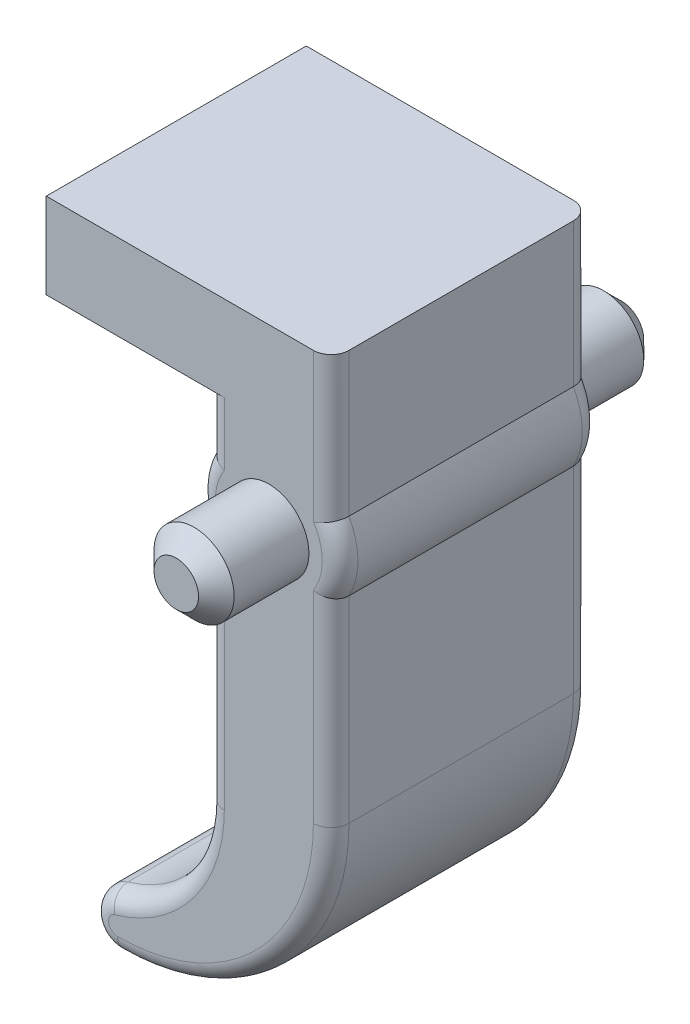
from build123d import *

# Parameters (mm, degrees)
BOSS_EXTRU_1_DEPTH = 7.3
ESQUISSE2_R        = 2.25
BOSS_EXTRU_2_DEPTH = 5.2
CHANFREIN1_SIZE    = 1
CHANFREIN2_SIZE    = 1
CONG_1_R           = 1


with BuildPart() as part:
    # Esquisse1 → Boss.-Extru.1 (new body, symmetric)
    with BuildSketch(Plane.XY):
        with BuildLine():
            Line((-3.5, -1.936491673), (-3.5, -14.854191767))
            ThreePointArc((-3.5, -14.854191767), (-5.005210596, -19.361130861), (-8.916666667, -22.059031961))
            ThreePointArc((-8.916666667, -22.059031961), (-9.985168687, -23.710413809), (-8.5, -25))
            ThreePointArc((-8.5, -25), (-0.014718626, -21.485281374), (3.5, -13))
            Line((3.5, -13), (3.5, -1.936491673))
            ThreePointArc((3.5, -1.936491673), (4, 0), (3.5, 1.936491673))
            Line((3.5, 1.936491673), (3.5, 10))
            Line((3.5, 10), (-3.5, 10))
            Line((-3.5, 10), (-12.5, 10))
            Line((-12.5, 10), (-12.5, 5.2))
            Line((-12.5, 5.2), (-3.5, 5.2))
            Line((-3.5, 5.2), (-3.5, 1.936491673))
            ThreePointArc((-3.5, 1.936491673), (-4, 0), (-3.5, -1.936491673))
        make_face()
    extrude(amount=BOSS_EXTRU_1_DEPTH, both=True)

    # Esquisse2 → Boss.-Extru.2 (add)
    with BuildSketch(Plane.XY.offset(7.3)):
        Circle(ESQUISSE2_R)
    boss_extru_2 = extrude(amount=BOSS_EXTRU_2_DEPTH)

    # Chanfrein1
    chanfrein1_edges = [part.edges().sort_by_distance(p)[0] for p in [
        (-2.25, 0, 12.5),
    ]]
    chamfer(chanfrein1_edges, length=CHANFREIN1_SIZE)

    # Symétrie1: Boss.-Extru.2 across plane
    add(boss_extru_2.mirror(Plane.XY))

    # Chanfrein2
    chanfrein2_edges = [part.edges().sort_by_distance(p)[0] for p in [
        (-2.25, 0, -12.5),
    ]]
    chamfer(chanfrein2_edges, length=CHANFREIN2_SIZE)

    # Congé1
    cong_1_edges = [part.edges().sort_by_distance(p)[0] for p in [
        (3.5, -7.468245837, 7.3),
        (-5.005210596, -19.361130861, -7.3),
        (-3.5, -8.39534172, -7.3),
        (-4, 0, -7.3),
        (-3.5, 3.568245837, -7.3),
        (3.5, 5.968245837, -7.3),
        (4, 0, -7.3),
        (4, 0, 7.3),
        (3.5, -7.468245837, -7.3),
        (-0.014718626, -21.485281374, -7.3),
        (-9.985168687, -23.710413809, -7.3),
        (3.5, 5.968245837, 7.3),
        (-3.5, 3.568245837, 7.3),
        (-4, 0, 7.3),
        (-3.5, -8.39534172, 7.3),
        (-9.985168687, -23.710413809, 7.3),
        (-5.005210596, -19.361130861, 7.3),
        (-0.014718626, -21.485281374, 7.3),
    ]]
    fillet(cong_1_edges, radius=CONG_1_R)


solid = part.part
